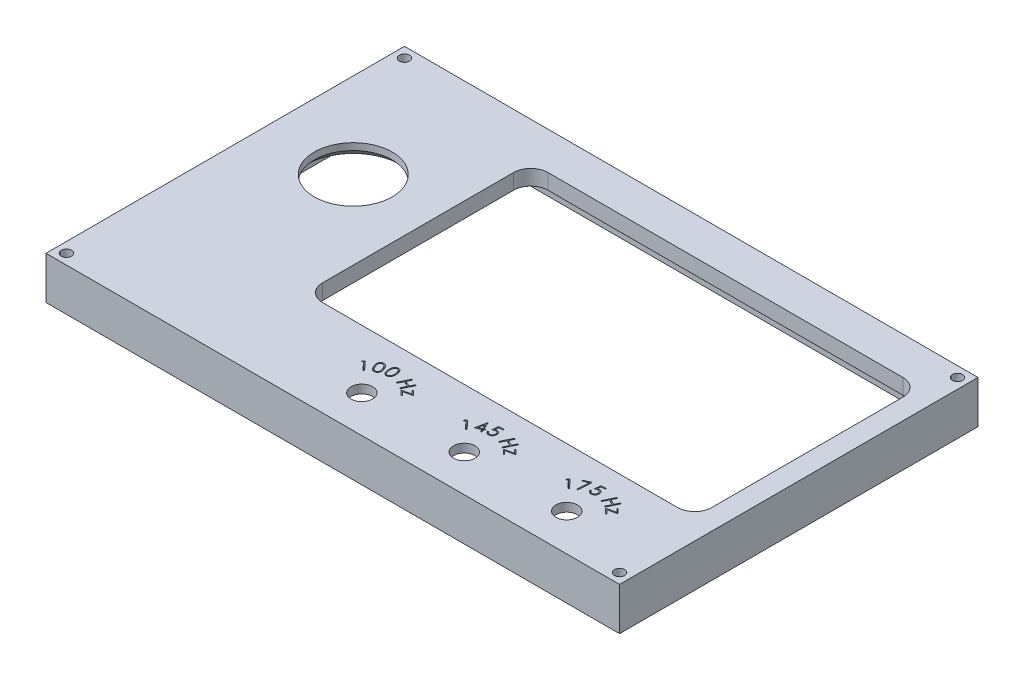
from build123d import *

# Parameters (mm, degrees)
SKETCH1_W           = 168
SKETCH1_H           = 105
SKETCH1_R           = 1.5
BOSS_EXTRUDE1_DEPTH = 12.5
SHELL1_T            = -4.5
SKETCH3_R           = 11.4
SKETCH3_R_2         = 3.15
CUT_EXTRUDE1_DEPTH  = 13.5
SKETCH5_R           = 1.5
CUT_EXTRUDE3_DEPTH  = 1.5
CUT_EXTRUDE2_DEPTH  = 3.5
CHAMFER1_SIZE       = 2.5
SKETCH7_W           = 12.3
SKETCH7_H           = 12.71
CUT_EXTRUDE5_DEPTH  = 2


with BuildPart() as part:
    # Sketch1 → Boss-Extrude1 (new body)
    with BuildSketch(Plane(origin=(0, 0, 0), x_dir=(1, 0, 0), z_dir=(0, 1, 0))):
        with Locations((-84, 52.5)):
            Rectangle(SKETCH1_W, SKETCH1_H)
        with Locations((-165, 102)):
            Circle(SKETCH1_R, mode=Mode.SUBTRACT)
        with Locations((-3, 102)):
            Circle(SKETCH1_R, mode=Mode.SUBTRACT)
        with Locations((-3, 3)):
            Circle(SKETCH1_R, mode=Mode.SUBTRACT)
        with Locations((-165, 3)):
            Circle(SKETCH1_R, mode=Mode.SUBTRACT)
    extrude(amount=BOSS_EXTRUDE1_DEPTH)

    # Shell1
    shell1_openings = [part.faces().sort_by_distance(p)[0] for p in [
        (-84, 0, -52.5),
    ]]
    offset(amount=SHELL1_T, openings=shell1_openings)

    # Sketch3 → Cut-Extrude1 (cut, through all)
    with BuildSketch(Plane(origin=(0, 12.5, 0), x_dir=(1, 0, 0), z_dir=(0, 1, 0))):
        with Locations((-143, 65)):
            Circle(SKETCH3_R)
        with Locations((-86.333333333, 10.85)):
            Circle(SKETCH3_R_2)
        with Locations((-56.333333333, 10.85)):
            Circle(SKETCH3_R_2)
        with Locations((-26.333333333, 10.85)):
            Circle(SKETCH3_R_2)
        with BuildLine():
            Line((-11, 28), (-115, 28))
            ThreePointArc((-115, 28), (-118.535533906, 29.464466094), (-120, 33))
            Line((-120, 33), (-120, 89))
            ThreePointArc((-120, 89), (-118.535533906, 92.535533906), (-115, 94))
            Line((-115, 94), (-11, 94))
            ThreePointArc((-11, 94), (-7.464466094, 92.535533906), (-6, 89))
            Line((-6, 89), (-6, 33))
            ThreePointArc((-6, 33), (-7.464466094, 29.464466094), (-11, 28))
        make_face()
    extrude(amount=-CUT_EXTRUDE1_DEPTH, mode=Mode.SUBTRACT)

    # Sketch5 → Cut-Extrude3 (cut)
    with BuildSketch(Plane.XZ.offset(-8)):
        with Locations((-132.8, -51.8)):
            Circle(SKETCH5_R)
        with Locations((-153.2, -79)):
            Circle(SKETCH5_R)
        with Locations((-132.8, -79)):
            Circle(SKETCH5_R)
        with Locations((-153.2, -51.8)):
            Circle(SKETCH5_R)
    extrude(amount=-CUT_EXTRUDE3_DEPTH, mode=Mode.SUBTRACT)

    # Sketch4 → Cut-Extrude2 (cut)
    with BuildSketch(Plane(origin=(0, 12.5, 0), x_dir=(1, 0, 0), z_dir=(0, 1, 0))):
        Polygon((-94.445283679, 19.011545498), (-93.945383839, 19.470780274), (-91.604338166, 16.924305915), (-91.856742012, 16.692234601), (-93.968520858, 18.989109601), (-94.368861403, 18.621020658), align=None)
        with BuildLine():
            add(Edge.make_bspline(
                [(-91.347504211, 19.330426391), (-91.369599216, 19.381693763), (-91.41251548, 19.481273013), (-91.469094071, 19.628778241), (-91.518404445, 19.768687315), (-91.559613275, 19.901651504), (-91.591581855, 20.027652599), (-91.616909663, 20.146584178), (-91.632823098, 20.258570372), (-91.641991895, 20.364177907), (-91.64188612, 20.464187128), (-91.638332743, 20.559973951), (-91.627860833, 20.652104802), (-91.610728108, 20.740265653), (-91.589394456, 20.825104101), (-91.561037989, 20.905842805), (-91.527422859, 20.983254228), (-91.488081557, 21.056750898), (-91.44410852, 21.126377666), (-91.394782816, 21.19065163), (-91.341930782, 21.250956337), (-91.284697772, 21.306059677), (-91.222967178, 21.356396579), (-91.157087354, 21.401849673), (-91.08686466, 21.442900877), (-91.037343747, 21.465741642), (-91.012367993, 21.477261327)],
                knots=[0, 0, 0, 0, 0.000167462, 0.000325271, 0.000473836, 0.000612447, 0.000742705, 0.000863709, 0.000977042, 0.001081847, 0.001181409, 0.001276854, 0.001369301, 0.001459231, 0.001546128, 0.001631495, 0.001715641, 0.001799074, 0.001881348, 0.0019624, 0.002041877, 0.00212171, 0.002200442, 0.002280569, 0.002361621, 0.002444094, 0.002444094, 0.002444094, 0.002444094], degree=3))
            add(Edge.make_bspline(
                [(-91.012367993, 21.477261327), (-90.986580778, 21.487962804), (-90.935451524, 21.509181014), (-90.856569255, 21.533440919), (-90.777223862, 21.552172817), (-90.696904461, 21.562825796), (-90.616330416, 21.569103467), (-90.535004005, 21.566973756), (-90.453110508, 21.560598523), (-90.370949502, 21.546006016), (-90.288608853, 21.526211496), (-90.207364756, 21.497489799), (-90.126497105, 21.463433911), (-90.046679764, 21.421472667), (-89.967706587, 21.372531354), (-89.889965691, 21.316200568), (-89.812985272, 21.253195857), (-89.736378177, 21.183254503), (-89.661238696, 21.104084744), (-89.586692259, 21.016338127), (-89.513842411, 20.918561927), (-89.442489181, 20.810850935), (-89.371596276, 20.693798297), (-89.302577454, 20.566785552), (-89.234197955, 20.430598044), (-89.191653852, 20.33554065), (-89.169819916, 20.28675652)],
                knots=[0, 0, 0, 0, 8.3716e-05, 0.000165986, 0.000247283, 0.000327995, 0.000408818, 0.00048946, 0.00057179, 0.000655011, 0.000739525, 0.000825554, 0.000913197, 0.001002573, 0.00109577, 0.0011917, 0.001290362, 0.001394074, 0.001502675, 0.001617584, 0.001739299, 0.001868223, 0.002005059, 0.002149704, 0.002301777, 0.002462101, 0.002462101, 0.002462101, 0.002462101], degree=3))
            add(Edge.make_bspline(
                [(-89.169819916, 20.28675652), (-89.148983399, 20.237789603), (-89.108331304, 20.142255033), (-89.053436794, 20.000788691), (-89.006833103, 19.864728965), (-88.969250854, 19.733984669), (-88.937682818, 19.609322849), (-88.915401311, 19.490089302), (-88.900232032, 19.376596431), (-88.893149729, 19.268368495), (-88.893340001, 19.164880135), (-88.898821207, 19.065855558), (-88.909796829, 18.970691869), (-88.92741581, 18.879597973), (-88.950497093, 18.792411603), (-88.979255717, 18.709078848), (-89.014336964, 18.629875819), (-89.055183708, 18.554799286), (-89.100602214, 18.48381319), (-89.151048082, 18.418128632), (-89.205581457, 18.357357497), (-89.26375601, 18.300866877), (-89.327050162, 18.249736964), (-89.394486304, 18.203625907), (-89.465637122, 18.161466882), (-89.515950243, 18.138316849), (-89.541414468, 18.12660027)],
                knots=[0, 0, 0, 0, 0.00015964, 0.000311459, 0.000455132, 0.000590926, 0.000719482, 0.000840766, 0.000954602, 0.001062803, 0.001165867, 0.001264885, 0.001360198, 0.001453014, 0.00154298, 0.001630564, 0.0017172, 0.001802532, 0.001886743, 0.00196976, 0.002050693, 0.002131517, 0.002212766, 0.002294446, 0.002376456, 0.002460497, 0.002460497, 0.002460497, 0.002460497], degree=3))
            add(Edge.make_bspline(
                [(-89.541414468, 18.12660027), (-89.566730992, 18.116116916), (-89.616923201, 18.095332756), (-89.694516732, 18.07197707), (-89.772330577, 18.05311246), (-89.851005132, 18.042237636), (-89.930000328, 18.037105016), (-90.009433942, 18.038889415), (-90.089681711, 18.045473302), (-90.17003496, 18.059797397), (-90.250303961, 18.080020017), (-90.329631707, 18.107366635), (-90.407611451, 18.142252224), (-90.485311311, 18.182808513), (-90.561358328, 18.231427049), (-90.636530891, 18.286482965), (-90.71130399, 18.34742108), (-90.784420463, 18.41673472), (-90.857188224, 18.494522158), (-90.929669079, 18.582141969), (-90.999764456, 18.681622081), (-91.071057863, 18.790581878), (-91.141344682, 18.910325699), (-91.211730553, 19.040462519), (-91.281018459, 19.181338943), (-91.324925549, 19.279796068), (-91.347504211, 19.330426391)],
                knots=[0, 0, 0, 0, 8.2154e-05, 0.000162877, 0.000242808, 0.000322131, 0.00040081, 0.000480049, 0.000560284, 0.000642123, 0.000724597, 0.00080841, 0.00089348, 0.000980667, 0.001071115, 0.001163952, 0.001260097, 0.001360287, 0.001465942, 0.001579502, 0.001701106, 0.001830816, 0.001970058, 0.002117503, 0.002274594, 0.002440895, 0.002440895, 0.002440895, 0.002440895], degree=3))
        make_face()
        with BuildLine():
            add(Edge.make_bspline(
                [(-91.043217352, 19.456628314), (-91.023803617, 19.413059835), (-90.986223146, 19.328721403), (-90.928023237, 19.207710442), (-90.869773299, 19.096686825), (-90.813415665, 18.994427761), (-90.756337235, 18.902543989), (-90.700599928, 18.819684379), (-90.645338392, 18.746455067), (-90.589865058, 18.682469213), (-90.534394726, 18.625959299), (-90.477507656, 18.576217313), (-90.421354412, 18.529974189), (-90.362454116, 18.490914985), (-90.303370376, 18.45608553), (-90.242308049, 18.428547329), (-90.181479403, 18.403756133), (-90.099189855, 18.381476481), (-89.997736184, 18.364156957), (-89.878320964, 18.362558703), (-89.763326187, 18.379176988), (-89.692012749, 18.40618249), (-89.656398442, 18.41966918)],
                knots=[0, 0, 0, 0, 0.000143091, 0.00027699, 0.000402743, 0.000519193, 0.000627179, 0.000727133, 0.000818701, 0.000902202, 0.000981031, 0.001056025, 0.00112884, 0.00119904, 0.001267829, 0.001334328, 0.001399818, 0.001464633, 0.001589695, 0.001707491, 0.001821725, 0.001935687, 0.001935687, 0.001935687, 0.001935687], degree=3))
            add(Edge.make_bspline(
                [(-89.656398442, 18.41966918), (-89.621977089, 18.436653865), (-89.55345027, 18.470467366), (-89.463740998, 18.543880471), (-89.384112223, 18.630762853), (-89.329213999, 18.715815321), (-89.292229634, 18.79065916), (-89.268306449, 18.850865826), (-89.249687699, 18.914323732), (-89.234373856, 18.980466173), (-89.22591835, 19.050250728), (-89.220768943, 19.123033994), (-89.220941179, 19.198924106), (-89.224232765, 19.250277883), (-89.22590966, 19.276440013)],
                knots=[0, 0, 0, 0, 0.000114821, 0.000228589, 0.000345222, 0.000467348, 0.000530686, 0.000595524, 0.000661403, 0.000728933, 0.00079894, 0.000872022, 0.000947743, 0.001026381, 0.001026381, 0.001026381, 0.001026381], degree=3))
            add(Edge.make_bspline(
                [(-89.22590966, 19.276440013), (-89.229043969, 19.30967268), (-89.235422568, 19.377304143), (-89.252163691, 19.479434555), (-89.272956197, 19.584614815), (-89.3004907, 19.692149675), (-89.333744601, 19.802689176), (-89.372166017, 19.915934315), (-89.416423423, 20.031915323), (-89.449532291, 20.109249633), (-89.466394436, 20.148635526)],
                knots=[0, 0, 0, 0, 0.000100113, 0.000203739, 0.000310303, 0.000421684, 0.000536587, 0.000656536, 0.000780367, 0.000908889, 0.000908889, 0.000908889, 0.000908889], degree=3))
            add(Edge.make_bspline(
                [(-89.466394436, 20.148635526), (-89.483899574, 20.187783825), (-89.518002363, 20.264050923), (-89.572312725, 20.37393448), (-89.627535654, 20.476805544), (-89.683565431, 20.572984168), (-89.740477649, 20.66243936), (-89.798242895, 20.744993319), (-89.857522795, 20.820342819), (-89.917127961, 20.889180712), (-89.9771257, 20.951876213), (-90.038641335, 21.007111161), (-90.099136759, 21.057278121), (-90.160788019, 21.100279852), (-90.222288151, 21.137471185), (-90.284128915, 21.168932766), (-90.346895864, 21.192475834), (-90.428640826, 21.216538284), (-90.529696135, 21.233342628), (-90.648027402, 21.234755381), (-90.762302204, 21.219384742), (-90.832808525, 21.192151744), (-90.867936903, 21.178583443)],
                knots=[0, 0, 0, 0, 0.000128642, 0.000250615, 0.00036762, 0.000478852, 0.000584463, 0.000685612, 0.000780988, 0.000871942, 0.000958714, 0.001041107, 0.001119839, 0.001194336, 0.001266361, 0.001335342, 0.00140214, 0.001467148, 0.001590826, 0.001707922, 0.001821356, 0.001933991, 0.001933991, 0.001933991, 0.001933991], degree=3))
            add(Edge.make_bspline(
                [(-90.867936903, 21.178583443), (-90.90239019, 21.161639202), (-90.971111925, 21.127841625), (-91.060819489, 21.053361902), (-91.141012582, 20.965405575), (-91.196187968, 20.879000454), (-91.234236644, 20.80373911), (-91.258017891, 20.742840675), (-91.277670622, 20.679374844), (-91.292287729, 20.612735477), (-91.303016178, 20.543206521), (-91.30818284, 20.470542933), (-91.309794053, 20.394933398), (-91.306125932, 20.315772729), (-91.297060889, 20.231621467), (-91.280398611, 20.141317521), (-91.257151284, 20.044292353), (-91.227241537, 19.940111833), (-91.1917921, 19.828846677), (-91.148449614, 19.710719864), (-91.098910342, 19.585630654), (-91.062144407, 19.500469278), (-91.043217352, 19.456628314)],
                knots=[0, 0, 0, 0, 0.000114821, 0.000229027, 0.000347169, 0.000470853, 0.000535131, 0.000599969, 0.000666723, 0.000734253, 0.000804456, 0.000877588, 0.000952622, 0.001031225, 0.001115155, 0.001206336, 0.001306501, 0.001414364, 0.001531437, 0.00165675, 0.001791763, 0.001935011, 0.001935011, 0.001935011, 0.001935011], degree=3))
        make_face(mode=Mode.SUBTRACT)
        with BuildLine():
            add(Edge.make_bspline(
                [(-88.321072717, 20.503335682), (-88.325111565, 20.559173035), (-88.33294722, 20.667501477), (-88.339432318, 20.825556425), (-88.340275276, 20.974293413), (-88.335659419, 21.113725948), (-88.325055466, 21.243776989), (-88.310024149, 21.364609892), (-88.289333939, 21.476170805), (-88.262364197, 21.578885738), (-88.230533294, 21.67403091), (-88.194913071, 21.763335969), (-88.154677957, 21.84707722), (-88.111005313, 21.925705422), (-88.061757147, 21.998297802), (-88.009928869, 22.066743939), (-87.951648651, 22.128144081), (-87.890881489, 22.185556433), (-87.82558333, 22.236147031), (-87.75843232, 22.282109277), (-87.688425242, 22.321489009), (-87.616173111, 22.355489003), (-87.54090325, 22.38251602), (-87.46347331, 22.404629414), (-87.383425674, 22.420013402), (-87.329037141, 22.425734442), (-87.301641627, 22.428616131)],
                knots=[0, 0, 0, 0, 0.000167943, 0.000325822, 0.000474461, 0.000614071, 0.000744204, 0.000865779, 0.000979225, 0.00108432, 0.001184092, 0.001280046, 0.001372557, 0.001462653, 0.001549575, 0.001635542, 0.001719875, 0.001803217, 0.001886109, 0.001967394, 0.002047141, 0.002126813, 0.002206661, 0.002286788, 0.002368191, 0.002450807, 0.002450807, 0.002450807, 0.002450807], degree=3))
            add(Edge.make_bspline(
                [(-87.301641627, 22.428616131), (-87.273840099, 22.430547756), (-87.218489829, 22.434393444), (-87.135990493, 22.430750364), (-87.054764062, 22.423016052), (-86.975448056, 22.40699611), (-86.897323429, 22.38610878), (-86.820613275, 22.358997911), (-86.746190928, 22.323755542), (-86.672549373, 22.284452592), (-86.601633261, 22.23780397), (-86.533185965, 22.185095079), (-86.468365801, 22.125405346), (-86.406062438, 22.059757198), (-86.347571252, 21.987576528), (-86.291705014, 21.909208591), (-86.239493543, 21.824181087), (-86.189077878, 21.732937577), (-86.143805233, 21.633352618), (-86.101289901, 21.525976293), (-86.064688211, 21.4093374), (-86.031714309, 21.284172799), (-86.002941092, 21.150382531), (-85.97972986, 21.007536407), (-85.958809004, 20.856365356), (-85.949659514, 20.752284043), (-85.944970954, 20.698948663)],
                knots=[0, 0, 0, 0, 8.3539e-05, 0.000166319, 0.000247386, 0.0003281, 0.000408717, 0.000489884, 0.000571759, 0.000655525, 0.000740117, 0.000826084, 0.00091442, 0.001004188, 0.001097374, 0.001192896, 0.001292707, 0.001396561, 0.001505418, 0.001620643, 0.001742817, 0.001871894, 0.002008859, 0.002153169, 0.00230597, 0.002466569, 0.002466569, 0.002466569, 0.002466569], degree=3))
            add(Edge.make_bspline(
                [(-85.944970954, 20.698948663), (-85.941176551, 20.645681928), (-85.93377615, 20.541793339), (-85.927783054, 20.389805565), (-85.928583833, 20.245721186), (-85.934593603, 20.109554468), (-85.946646259, 19.981386626), (-85.962884216, 19.860924852), (-85.98610044, 19.74855124), (-86.014866991, 19.643689044), (-86.048760419, 19.54571269), (-86.086768898, 19.453866768), (-86.127804679, 19.367010594), (-86.174352462, 19.286386831), (-86.224564394, 19.211107822), (-86.279845606, 19.142060986), (-86.338634112, 19.078070233), (-86.401632441, 19.019794973), (-86.468483291, 18.968199575), (-86.537095126, 18.921636759), (-86.608282576, 18.881327604), (-86.682308109, 18.847681148), (-86.758756266, 18.81969057), (-86.837411921, 18.797122953), (-86.918522479, 18.780609801), (-86.973684592, 18.775067065), (-87.001561499, 18.77226597)],
                knots=[0, 0, 0, 0, 0.000160201, 0.000312448, 0.00045618, 0.000592344, 0.000721201, 0.000842268, 0.000956809, 0.001065159, 0.001168262, 0.001267606, 0.001363252, 0.001456216, 0.001546639, 0.001634456, 0.001721285, 0.001807123, 0.001891552, 0.001974391, 0.002055703, 0.002136649, 0.002218054, 0.002299722, 0.002381948, 0.002465957, 0.002465957, 0.002465957, 0.002465957], degree=3))
            add(Edge.make_bspline(
                [(-87.001561499, 18.77226597), (-87.029129034, 18.770708126), (-87.083548279, 18.767632889), (-87.164896731, 18.7698345), (-87.244629807, 18.778108273), (-87.322924061, 18.792994587), (-87.399453989, 18.813869712), (-87.474157266, 18.841856444), (-87.547846715, 18.874381858), (-87.619471088, 18.913994411), (-87.68897146, 18.959250813), (-87.75478914, 19.011725585), (-87.818540795, 19.069112235), (-87.877722553, 19.133927374), (-87.934181485, 19.204421906), (-87.987177689, 19.281023194), (-88.03816961, 19.363279564), (-88.085077522, 19.452833075), (-88.129103907, 19.550195147), (-88.168034219, 19.657460179), (-88.203656532, 19.774225333), (-88.235010192, 19.901154592), (-88.262938728, 20.037497885), (-88.286717877, 20.183922887), (-88.306160974, 20.34018488), (-88.316007384, 20.44791539), (-88.321072717, 20.503335682)],
                knots=[0, 0, 0, 0, 8.2807e-05, 0.000163463, 0.000243833, 0.000323038, 0.000402302, 0.000481491, 0.000562148, 0.000643731, 0.000726766, 0.000810643, 0.000896007, 0.000983827, 0.001073614, 0.001166779, 0.001263099, 0.001363772, 0.001469844, 0.001583417, 0.001705842, 0.001835928, 0.001975494, 0.002123263, 0.00228084, 0.002447787, 0.002447787, 0.002447787, 0.002447787], degree=3))
        make_face()
        with BuildLine():
            add(Edge.make_bspline(
                [(-87.990844351, 20.523668214), (-87.986701643, 20.475961327), (-87.978689112, 20.383690056), (-87.962209504, 20.250260662), (-87.944356093, 20.126023276), (-87.923487712, 20.010913087), (-87.899527594, 19.90504301), (-87.874148135, 19.808183025), (-87.845253734, 19.720966599), (-87.814287294, 19.642234036), (-87.780425589, 19.570476899), (-87.742779853, 19.504725302), (-87.704146898, 19.442757385), (-87.661480433, 19.386397134), (-87.616819713, 19.334327418), (-87.568976644, 19.287196328), (-87.518376311, 19.244893103), (-87.448235741, 19.196240569), (-87.357517933, 19.146924679), (-87.244928999, 19.105952024), (-87.130158624, 19.085223737), (-87.053743225, 19.087390094), (-87.015583934, 19.0884719)],
                knots=[0, 0, 0, 0, 0.000143648, 0.000277833, 0.000403264, 0.000520156, 0.000628676, 0.000728848, 0.000820416, 0.000904132, 0.000982535, 0.001058195, 0.001131327, 0.001201439, 0.001270034, 0.001336965, 0.001402676, 0.001467639, 0.001592812, 0.001711237, 0.001825812, 0.001940097, 0.001940097, 0.001940097, 0.001940097], degree=3))
            add(Edge.make_bspline(
                [(-87.015583934, 19.0884719), (-86.977654776, 19.093418262), (-86.90180927, 19.103309317), (-86.792759043, 19.142947004), (-86.68895891, 19.19960637), (-86.60931835, 19.262235213), (-86.549013229, 19.320094794), (-86.50680478, 19.369451644), (-86.468526739, 19.42380013), (-86.432409595, 19.481727253), (-86.401078262, 19.544932653), (-86.37212125, 19.611891059), (-86.347703582, 19.684037041), (-86.334068795, 19.733897147), (-86.327082332, 19.759445457)],
                knots=[0, 0, 0, 0, 0.000114457, 0.000228875, 0.000345599, 0.00046803, 0.000531496, 0.000596137, 0.000662481, 0.000730782, 0.000800704, 0.000873893, 0.000949501, 0.001028954, 0.001028954, 0.001028954, 0.001028954], degree=3))
            add(Edge.make_bspline(
                [(-86.327082332, 19.759445457), (-86.319278289, 19.791859254), (-86.303360468, 19.857973322), (-86.285261435, 19.960260494), (-86.272545371, 20.067048655), (-86.26190169, 20.178047778), (-86.258713631, 20.293676142), (-86.257443373, 20.413620417), (-86.261910364, 20.537804862), (-86.267930161, 20.621841879), (-86.270992588, 20.664593695)],
                knots=[0, 0, 0, 0, 0.000100005, 0.000203979, 0.000311379, 0.000422591, 0.000538352, 0.000658246, 0.000782416, 0.000910997, 0.000910997, 0.000910997, 0.000910997], degree=3))
            add(Edge.make_bspline(
                [(-86.270992588, 20.664593695), (-86.274968005, 20.70738575), (-86.282735121, 20.790992304), (-86.297998603, 20.913110776), (-86.317019257, 21.02881795), (-86.33868315, 21.138272414), (-86.362946732, 21.241561825), (-86.391073576, 21.338659196), (-86.422366972, 21.429487061), (-86.45692885, 21.514151595), (-86.493938002, 21.592548917), (-86.533318308, 21.665084759), (-86.5746709, 21.731868793), (-86.618167446, 21.793221198), (-86.664221731, 21.84892706), (-86.713684272, 21.897687273), (-86.7640191, 21.942069962), (-86.834619658, 21.990285308), (-86.92423686, 22.040099443), (-87.036263783, 22.079866536), (-87.149574237, 22.101867864), (-87.22536991, 22.099543959), (-87.263079928, 22.098387765)],
                knots=[0, 0, 0, 0, 0.000128924, 0.000251891, 0.000369115, 0.000480628, 0.000586574, 0.000687312, 0.000783764, 0.000874642, 0.000961516, 0.001043715, 0.001122122, 0.001197024, 0.001269198, 0.001338606, 0.001405223, 0.001470186, 0.001594743, 0.001711612, 0.001825619, 0.001938502, 0.001938502, 0.001938502, 0.001938502], degree=3))
            add(Edge.make_bspline(
                [(-87.263079928, 22.098387765), (-87.301226467, 22.093150865), (-87.377239061, 22.082715571), (-87.487151659, 22.043351719), (-87.591208299, 21.984814244), (-87.671896388, 21.921345896), (-87.732978686, 21.862831559), (-87.775276644, 21.812973861), (-87.814496088, 21.759118667), (-87.85026267, 21.700697554), (-87.882607328, 21.638132544), (-87.91108464, 21.571164571), (-87.937522741, 21.500300008), (-87.959011434, 21.423783724), (-87.977643504, 21.341023702), (-87.991164503, 21.250072198), (-88.001778037, 21.150444175), (-88.007793975, 21.041875793), (-88.009777133, 20.924709741), (-88.007525526, 20.798910724), (-88.00103468, 20.664266783), (-87.99431584, 20.571565229), (-87.990844351, 20.523668214)],
                knots=[0, 0, 0, 0, 0.000115266, 0.000229684, 0.0003477, 0.000472099, 0.000536556, 0.000601197, 0.000667951, 0.000736252, 0.000806493, 0.000879038, 0.000954454, 0.001033233, 0.001117265, 0.00120879, 0.001308903, 0.00141776, 0.001534866, 0.001660385, 0.001795148, 0.001939213, 0.001939213, 0.001939213, 0.001939213], degree=3))
        make_face(mode=Mode.SUBTRACT)
        Polygon((-82.44064603, 21.69454161), (-82.126543465, 21.542398181), (-82.763162055, 20.231300424), (-81.173017824, 19.459365328), (-80.536399235, 20.770463085), (-80.222296671, 20.617618533), (-81.740225357, 17.49131645), (-82.054327921, 17.644161001), (-81.321655645, 19.152975104), (-82.911799876, 19.9249102), (-83.644472151, 18.416096098), (-83.958574715, 18.568239527), align=None)
        Polygon((-79.431135966, 19.035351656), (-78.082878754, 17.696209027), (-80.737325869, 17.101657745), (-79.731917216, 16.103260309), (-79.939449267, 15.894326015), (-81.351508562, 17.296569604), (-78.695659203, 17.89252313), (-79.637265773, 18.827819604), align=None)
        Polygon((-49.43113597, 19.035351659), (-48.082878759, 17.696209031), (-50.737325874, 17.101657749), (-49.73191722, 16.103260313), (-49.939449271, 15.894326018), (-51.351508566, 17.296569608), (-48.695659207, 17.892523133), (-49.637265778, 18.827819608), align=None)
        Polygon((-52.440646036, 21.694541612), (-52.126543472, 21.542398183), (-52.763162062, 20.231300426), (-51.173017831, 19.45936533), (-50.536399241, 20.770463086), (-50.222296677, 20.617618535), (-51.740225363, 17.491316452), (-52.054327927, 17.644161003), (-51.321655652, 19.152975106), (-52.911799883, 19.924910202), (-53.644472158, 18.416096099), (-53.958574722, 18.568239529), align=None)
        with BuildLine():
            Line((-56.234534259, 22.427915008), (-56.207190509, 22.096284399))
            Line((-56.207190509, 22.096284399), (-57.447474964, 21.994621738))
            Line((-57.447474964, 21.994621738), (-57.542126407, 21.031981514))
            add(Edge.make_bspline(
                [(-57.542126407, 21.031981514), (-57.506041498, 21.045021288), (-57.436346012, 21.070206702), (-57.332729754, 21.10000041), (-57.234037828, 21.120800552), (-57.169435046, 21.128046459), (-57.138280253, 21.131540809)],
                knots=[0, 0, 0, 0, 0.00011508, 0.000222269, 0.000323197, 0.000417205, 0.000417205, 0.000417205, 0.000417205], degree=3))
            add(Edge.make_bspline(
                [(-57.138280253, 21.131540809), (-57.099496537, 21.133623356), (-57.023075458, 21.137726895), (-56.910329358, 21.132100302), (-56.801833595, 21.11588103), (-56.697857215, 21.089422191), (-56.598100988, 21.05171149), (-56.502796368, 21.004249143), (-56.412150538, 20.945794159), (-56.326497879, 20.878378942), (-56.247658361, 20.802215572), (-56.176957105, 20.719377804), (-56.116625284, 20.629368951), (-56.064127694, 20.533959296), (-56.022429862, 20.431355471), (-55.988287675, 20.322961836), (-55.964553871, 20.207794073), (-55.956219941, 20.128561158), (-55.951982176, 20.088271578)],
                knots=[0, 0, 0, 0, 0.000116462, 0.000229482, 0.000337959, 0.000445091, 0.000550702, 0.00065731, 0.000763889, 0.000873717, 0.000983796, 0.001092241, 0.001199778, 0.001308332, 0.001418354, 0.00153145, 0.001648879, 0.001770368, 0.001770368, 0.001770368, 0.001770368], degree=3))
            add(Edge.make_bspline(
                [(-55.951982176, 20.088271578), (-55.950231486, 20.059770907), (-55.946775156, 20.003502979), (-55.947696432, 19.919436475), (-55.953207956, 19.837028534), (-55.963618508, 19.755698954), (-55.979934173, 19.675906346), (-56.000847693, 19.597418705), (-56.026969397, 19.520311587), (-56.058420925, 19.445262719), (-56.093946647, 19.372649415), (-56.133346954, 19.303447431), (-56.176766137, 19.238373099), (-56.224030473, 19.176960194), (-56.275094105, 19.119293632), (-56.330867616, 19.066138017), (-56.389624713, 19.016170882), (-56.452230344, 18.970536268), (-56.518302356, 18.929088438), (-56.587419161, 18.892090444), (-56.659598999, 18.859623886), (-56.734676166, 18.831429238), (-56.81321208, 18.808391053), (-56.894791486, 18.790390816), (-56.979027505, 18.776124389), (-57.036342048, 18.770304865), (-57.065363586, 18.767358117)],
                knots=[0, 0, 0, 0, 8.564e-05, 0.000169077, 0.000251999, 0.000333311, 0.000414849, 0.000496143, 0.000576848, 0.00065888, 0.000740092, 0.000819229, 0.000897594, 0.000974584, 0.001051557, 0.001128416, 0.00120553, 0.001282799, 0.001360611, 0.001439343, 0.001517794, 0.001597884, 0.001679748, 0.001763096, 0.001848391, 0.001935882, 0.001935882, 0.001935882, 0.001935882], degree=3))
            add(Edge.make_bspline(
                [(-57.065363586, 18.767358117), (-57.100170743, 18.765437444), (-57.168376772, 18.761673808), (-57.269558038, 18.764941424), (-57.367044001, 18.777966216), (-57.461606709, 18.797848955), (-57.552244607, 18.827443947), (-57.638980816, 18.865949206), (-57.723005716, 18.911330442), (-57.802408059, 18.965926908), (-57.87626959, 19.027707032), (-57.944913874, 19.09400671), (-58.005324027, 19.167096084), (-58.059645361, 19.244982466), (-58.106606954, 19.32868167), (-58.14651748, 19.417720382), (-58.180805451, 19.511482565), (-58.19666311, 19.576971512), (-58.204686503, 19.610106514)],
                knots=[0, 0, 0, 0, 0.000104552, 0.000204873, 0.000303143, 0.000399268, 0.000494386, 0.000588569, 0.000683638, 0.000780484, 0.000877076, 0.000972269, 0.001066347, 0.001161063, 0.001256812, 0.001353772, 0.001453568, 0.001555774, 0.001555774, 0.001555774, 0.001555774], degree=3))
            Line((-58.204686503, 19.610106514), (-57.847114388, 19.639553629))
            add(Edge.make_bspline(
                [(-57.847114388, 19.639553629), (-57.837298446, 19.607975092), (-57.818407869, 19.547202852), (-57.779686922, 19.463218264), (-57.736878284, 19.38818505), (-57.686178971, 19.323194799), (-57.628271566, 19.267063669), (-57.563537059, 19.217873106), (-57.491306201, 19.175471811), (-57.412649016, 19.140978325), (-57.329768449, 19.114199284), (-57.244333583, 19.097652059), (-57.157810301, 19.089150338), (-57.099960962, 19.091967877), (-57.070972561, 19.093379751)],
                knots=[0, 0, 0, 0, 9.9106e-05, 0.000190728, 0.000276827, 0.000357751, 0.00043708, 0.000518131, 0.000601101, 0.000687737, 0.000775321, 0.00086181, 0.000948392, 0.001035356, 0.001035356, 0.001035356, 0.001035356], degree=3))
            add(Edge.make_bspline(
                [(-57.070972561, 19.093379751), (-57.042832223, 19.096525685), (-56.987459999, 19.102715992), (-56.90690189, 19.122138544), (-56.83008799, 19.148853421), (-56.756664344, 19.183097103), (-56.687675167, 19.226504193), (-56.622163999, 19.277233463), (-56.560284992, 19.335805356), (-56.502651944, 19.401323835), (-56.449990022, 19.472157115), (-56.405952324, 19.548051926), (-56.36986719, 19.62723324), (-56.341803464, 19.709679112), (-56.321176711, 19.79554921), (-56.30972019, 19.885066243), (-56.304954729, 19.97798771), (-56.308931344, 20.040838533), (-56.310956535, 20.072846899)],
                knots=[0, 0, 0, 0, 8.4879e-05, 0.000167018, 0.000247951, 0.000328556, 0.000409489, 0.000491951, 0.000576764, 0.000664684, 0.00075345, 0.000841112, 0.000927396, 0.001014089, 0.001102009, 0.001191846, 0.001284489, 0.001380635, 0.001380635, 0.001380635, 0.001380635], degree=3))
            add(Edge.make_bspline(
                [(-56.310956535, 20.072846899), (-56.313993243, 20.101424306), (-56.319956428, 20.157541766), (-56.336730781, 20.239095195), (-56.360713515, 20.315782055), (-56.390898516, 20.388053524), (-56.42822448, 20.455386207), (-56.471820814, 20.51840839), (-56.522686997, 20.575968344), (-56.579533959, 20.628577528), (-56.641415536, 20.675309301), (-56.708136712, 20.715159379), (-56.779071005, 20.74712642), (-56.85383866, 20.772823942), (-56.93292334, 20.79008679), (-57.015741419, 20.800402452), (-57.102799115, 20.804328735), (-57.161896742, 20.800483829), (-57.192266631, 20.798507956)],
                knots=[0, 0, 0, 0, 8.6181e-05, 0.000169234, 0.000249287, 0.000326897, 0.000403781, 0.000479829, 0.000556338, 0.000633735, 0.00071184, 0.000788555, 0.000866367, 0.000944855, 0.001025313, 0.001108711, 0.00119502, 0.001286263, 0.001286263, 0.001286263, 0.001286263], degree=3))
            add(Edge.make_bspline(
                [(-57.192266631, 20.798507956), (-57.218504453, 20.795906452), (-57.27271809, 20.790531118), (-57.35498863, 20.773636293), (-57.441005205, 20.751642203), (-57.530712517, 20.724724176), (-57.623533381, 20.689664844), (-57.719992943, 20.648936387), (-57.820532063, 20.602832167), (-57.887684026, 20.56811929), (-57.92213442, 20.550310841)],
                knots=[0, 0, 0, 0, 7.9053e-05, 0.000163342, 0.000251597, 0.000345414, 0.000444133, 0.000549086, 0.00065951, 0.000775839, 0.000775839, 0.000775839, 0.000775839], degree=3))
            Line((-57.92213442, 20.550310841), (-57.741946118, 22.304517572))
            Line((-57.741946118, 22.304517572), (-56.234534259, 22.427915008))
        make_face()
        Polygon((-60.332980975, 21.775238089), (-60.267776649, 21.803984083), (-59.29181511, 19.580726871), (-58.906198123, 19.750398345), (-58.771582738, 19.444709243), (-59.157199725, 19.275037769), (-58.831879213, 18.53325091), (-59.150889629, 18.393026551), (-59.476210142, 19.13481341), (-61.001150046, 18.465943217), align=None)
        Polygon((-59.610825527, 19.440502512), (-60.194859982, 20.770530557), (-60.550328732, 19.028242897), align=None, mode=Mode.SUBTRACT)
        Polygon((-64.445283689, 19.011545485), (-63.945383849, 19.470780261), (-61.604338176, 16.924305902), (-61.856742022, 16.692234588), (-63.968520868, 18.989109588), (-64.368861413, 18.621020645), align=None)
        Polygon((-34.44528369, 19.011545484), (-33.94538385, 19.47078026), (-31.604338177, 16.924305901), (-31.856742023, 16.692234587), (-33.968520869, 18.989109587), (-34.368861414, 18.621020644), align=None)
        Polygon((-31.870541079, 21.005406354), (-29.847103579, 21.893727668), (-30.118437713, 17.873495296), (-30.439551496, 17.892425584), (-30.208882425, 21.374897539), (-31.73802906, 20.703923982), align=None)
        with BuildLine():
            Line((-26.234534262, 22.427915007), (-26.207190512, 22.096284398))
            Line((-26.207190512, 22.096284398), (-27.447474967, 21.994621738))
            Line((-27.447474967, 21.994621738), (-27.542126409, 21.031981514))
            add(Edge.make_bspline(
                [(-27.542126409, 21.031981514), (-27.506041501, 21.045021287), (-27.436346014, 21.070206701), (-27.332729757, 21.10000041), (-27.23403783, 21.120800551), (-27.169435048, 21.128046458), (-27.138280255, 21.131540808)],
                knots=[0, 0, 0, 0, 0.00011508, 0.000222269, 0.000323197, 0.000417205, 0.000417205, 0.000417205, 0.000417205], degree=3))
            add(Edge.make_bspline(
                [(-27.138280255, 21.131540808), (-27.099496539, 21.133623356), (-27.02307546, 21.137726895), (-26.91032936, 21.132100302), (-26.801833597, 21.115881029), (-26.697857217, 21.08942219), (-26.598100991, 21.051711489), (-26.50279637, 21.004249143), (-26.41215054, 20.945794159), (-26.326497882, 20.878378941), (-26.247658363, 20.802215571), (-26.176957108, 20.719377803), (-26.116625286, 20.62936895), (-26.064127697, 20.533959296), (-26.022429864, 20.43135547), (-25.988287677, 20.322961836), (-25.964553873, 20.207794073), (-25.956219944, 20.128561157), (-25.951982178, 20.088271578)],
                knots=[0, 0, 0, 0, 0.000116462, 0.000229482, 0.000337959, 0.000445091, 0.000550702, 0.00065731, 0.000763889, 0.000873717, 0.000983796, 0.001092241, 0.001199778, 0.001308332, 0.001418354, 0.00153145, 0.001648879, 0.001770368, 0.001770368, 0.001770368, 0.001770368], degree=3))
            add(Edge.make_bspline(
                [(-25.951982178, 20.088271578), (-25.950231488, 20.059770906), (-25.946775158, 20.003502978), (-25.947696435, 19.919436474), (-25.953207958, 19.837028534), (-25.963618511, 19.755698954), (-25.979934175, 19.675906346), (-26.000847695, 19.597418704), (-26.026969399, 19.520311587), (-26.058420928, 19.445262718), (-26.093946649, 19.372649415), (-26.133346956, 19.30344743), (-26.176766139, 19.238373099), (-26.224030475, 19.176960193), (-26.275094107, 19.119293632), (-26.330867618, 19.066138016), (-26.389624715, 19.016170882), (-26.452230346, 18.970536268), (-26.518302358, 18.929088437), (-26.587419163, 18.892090443), (-26.659599001, 18.859623885), (-26.734676168, 18.831429238), (-26.813212082, 18.808391052), (-26.894791488, 18.790390816), (-26.979027507, 18.776124388), (-27.036342051, 18.770304864), (-27.065363588, 18.767358116)],
                knots=[0, 0, 0, 0, 8.564e-05, 0.000169077, 0.000251999, 0.000333311, 0.000414849, 0.000496143, 0.000576848, 0.00065888, 0.000740092, 0.000819229, 0.000897594, 0.000974584, 0.001051557, 0.001128416, 0.00120553, 0.001282799, 0.001360611, 0.001439343, 0.001517794, 0.001597884, 0.001679748, 0.001763096, 0.001848391, 0.001935882, 0.001935882, 0.001935882, 0.001935882], degree=3))
            add(Edge.make_bspline(
                [(-27.065363588, 18.767358116), (-27.100170745, 18.765437443), (-27.168376774, 18.761673807), (-27.26955804, 18.764941423), (-27.367044003, 18.777966216), (-27.461606711, 18.797848954), (-27.552244609, 18.827443946), (-27.638980818, 18.865949205), (-27.723005718, 18.911330441), (-27.802408061, 18.965926907), (-27.876269593, 19.027707031), (-27.944913876, 19.094006709), (-28.005324029, 19.167096084), (-28.059645364, 19.244982466), (-28.106606956, 19.328681669), (-28.146517482, 19.417720381), (-28.180805453, 19.511482564), (-28.196663112, 19.576971512), (-28.204686505, 19.610106514)],
                knots=[0, 0, 0, 0, 0.000104552, 0.000204873, 0.000303143, 0.000399268, 0.000494386, 0.000588569, 0.000683638, 0.000780484, 0.000877076, 0.000972269, 0.001066347, 0.001161063, 0.001256812, 0.001353772, 0.001453568, 0.001555774, 0.001555774, 0.001555774, 0.001555774], degree=3))
            Line((-28.204686505, 19.610106514), (-27.84711439, 19.639553629))
            add(Edge.make_bspline(
                [(-27.84711439, 19.639553629), (-27.837298448, 19.607975092), (-27.818407871, 19.547202852), (-27.779686924, 19.463218263), (-27.736878286, 19.388185049), (-27.686178973, 19.323194798), (-27.628271568, 19.267063669), (-27.563537062, 19.217873105), (-27.491306204, 19.175471811), (-27.412649018, 19.140978324), (-27.329768451, 19.114199283), (-27.244333585, 19.097652058), (-27.157810303, 19.089150337), (-27.099960964, 19.091967877), (-27.070972563, 19.093379751)],
                knots=[0, 0, 0, 0, 9.9106e-05, 0.000190728, 0.000276827, 0.000357751, 0.00043708, 0.000518131, 0.000601101, 0.000687737, 0.000775321, 0.00086181, 0.000948392, 0.001035356, 0.001035356, 0.001035356, 0.001035356], degree=3))
            add(Edge.make_bspline(
                [(-27.070972563, 19.093379751), (-27.042832226, 19.096525684), (-26.987460001, 19.102715992), (-26.906901892, 19.122138544), (-26.830087992, 19.14885342), (-26.756664346, 19.183097102), (-26.687675169, 19.226504193), (-26.622164001, 19.277233463), (-26.560284994, 19.335805356), (-26.502651946, 19.401323834), (-26.449990024, 19.472157114), (-26.405952327, 19.548051925), (-26.369867192, 19.627233239), (-26.341803466, 19.709679111), (-26.321176713, 19.795549209), (-26.309720192, 19.885066242), (-26.304954731, 19.97798771), (-26.308931346, 20.040838532), (-26.310956537, 20.072846898)],
                knots=[0, 0, 0, 0, 8.4879e-05, 0.000167018, 0.000247951, 0.000328556, 0.000409489, 0.000491951, 0.000576764, 0.000664684, 0.00075345, 0.000841112, 0.000927396, 0.001014089, 0.001102009, 0.001191846, 0.001284489, 0.001380635, 0.001380635, 0.001380635, 0.001380635], degree=3))
            add(Edge.make_bspline(
                [(-26.310956537, 20.072846898), (-26.313993246, 20.101424306), (-26.319956431, 20.157541765), (-26.336730783, 20.239095195), (-26.360713517, 20.315782054), (-26.390898518, 20.388053523), (-26.428224483, 20.455386206), (-26.471820817, 20.518408389), (-26.522686999, 20.575968343), (-26.579533961, 20.628577527), (-26.641415539, 20.675309301), (-26.708136714, 20.715159378), (-26.779071007, 20.74712642), (-26.853838662, 20.772823941), (-26.932923342, 20.79008679), (-27.015741421, 20.800402451), (-27.102799117, 20.804328734), (-27.161896744, 20.800483828), (-27.192266633, 20.798507956)],
                knots=[0, 0, 0, 0, 8.6181e-05, 0.000169234, 0.000249287, 0.000326897, 0.000403781, 0.000479829, 0.000556338, 0.000633735, 0.00071184, 0.000788555, 0.000866367, 0.000944855, 0.001025313, 0.001108711, 0.00119502, 0.001286263, 0.001286263, 0.001286263, 0.001286263], degree=3))
            add(Edge.make_bspline(
                [(-27.192266633, 20.798507956), (-27.218504455, 20.795906451), (-27.272718093, 20.790531118), (-27.354988633, 20.773636292), (-27.441005207, 20.751642203), (-27.530712519, 20.724724176), (-27.623533383, 20.689664843), (-27.719992945, 20.648936386), (-27.820532065, 20.602832166), (-27.887684028, 20.568119289), (-27.922134422, 20.55031084)],
                knots=[0, 0, 0, 0, 7.9053e-05, 0.000163342, 0.000251597, 0.000345414, 0.000444133, 0.000549086, 0.00065951, 0.000775839, 0.000775839, 0.000775839, 0.000775839], degree=3))
            Line((-27.922134422, 20.55031084), (-27.74194612, 22.304517571))
            Line((-27.74194612, 22.304517571), (-26.234534262, 22.427915007))
        make_face()
        Polygon((-22.440646027, 21.69454161), (-22.126543463, 21.54239818), (-22.763162053, 20.231300424), (-21.173017822, 19.459365328), (-20.536399232, 20.770463084), (-20.222296668, 20.617618533), (-21.740225354, 17.49131645), (-22.054327918, 17.644161001), (-21.321655643, 19.152975103), (-22.911799873, 19.9249102), (-23.644472149, 18.416096097), (-23.958574713, 18.568239526), align=None)
        Polygon((-19.43113597, 19.035351659), (-18.082878759, 17.696209031), (-20.737325874, 17.101657749), (-19.73191722, 16.103260313), (-19.939449271, 15.894326018), (-21.351508566, 17.296569608), (-18.695659207, 17.892523134), (-19.637265778, 18.827819608), align=None)
    extrude(amount=-CUT_EXTRUDE2_DEPTH, mode=Mode.SUBTRACT)

    # Chamfer1
    chamfer1_edges = [part.edges().sort_by_distance(p)[0] for p in [
        (-154.4, 8, -65),
    ]]
    chamfer(chamfer1_edges, length=CHAMFER1_SIZE)

    # Sketch7 → Cut-Extrude5 (cut)
    with BuildSketch(Plane.XZ.offset(-8)):
        with Locations((-86.333333333, -10.85)):
            Rectangle(SKETCH7_W, SKETCH7_H)
        with Locations((-56.333333333, -10.85)):
            Rectangle(SKETCH7_W, SKETCH7_H)
        with Locations((-26.333333333, -10.85)):
            Rectangle(SKETCH7_W, SKETCH7_H)
    extrude(amount=-CUT_EXTRUDE5_DEPTH, mode=Mode.SUBTRACT)


solid = part.part
